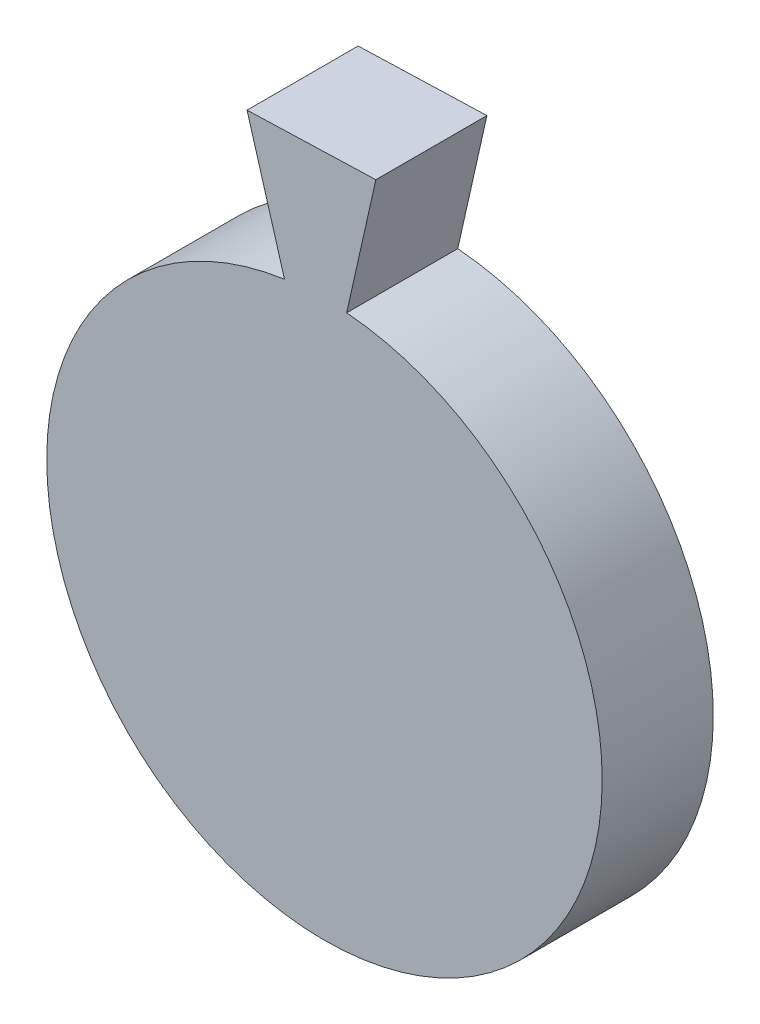
from build123d import *

# Parameters (mm, degrees)
SKETCH_1_R      = 12.5
EXTRUDE_1_DEPTH = 5
EXTRUDE_2_DEPTH = 5


with BuildPart() as part:
    # ｽｹｯﾁ1 → ﾎﾞｽ - 押し出し1 (new body)
    with BuildSketch(Plane.XY):
        with Locations((-14.880131723, 17.607142857)):
            Circle(SKETCH_1_R)
    extrude(amount=EXTRUDE_1_DEPTH)

    # ｽｹｯﾁ2 → ﾎﾞｽ - 押し出し2 (add)
    with BuildSketch(Plane(origin=(0, 0, 0), x_dir=(-1, 0, 0), z_dir=(0, 0, -1))):
        Polygon((13.880131723, 30.067078652), (16.678684785, 29.977074421), (18.364346975, 35.725860639), (16.86512212, 35.774077191), (14.066569059, 35.864081422), (12.567344204, 35.912297974), align=None)
    extrude(amount=-EXTRUDE_2_DEPTH)


solid = part.part
